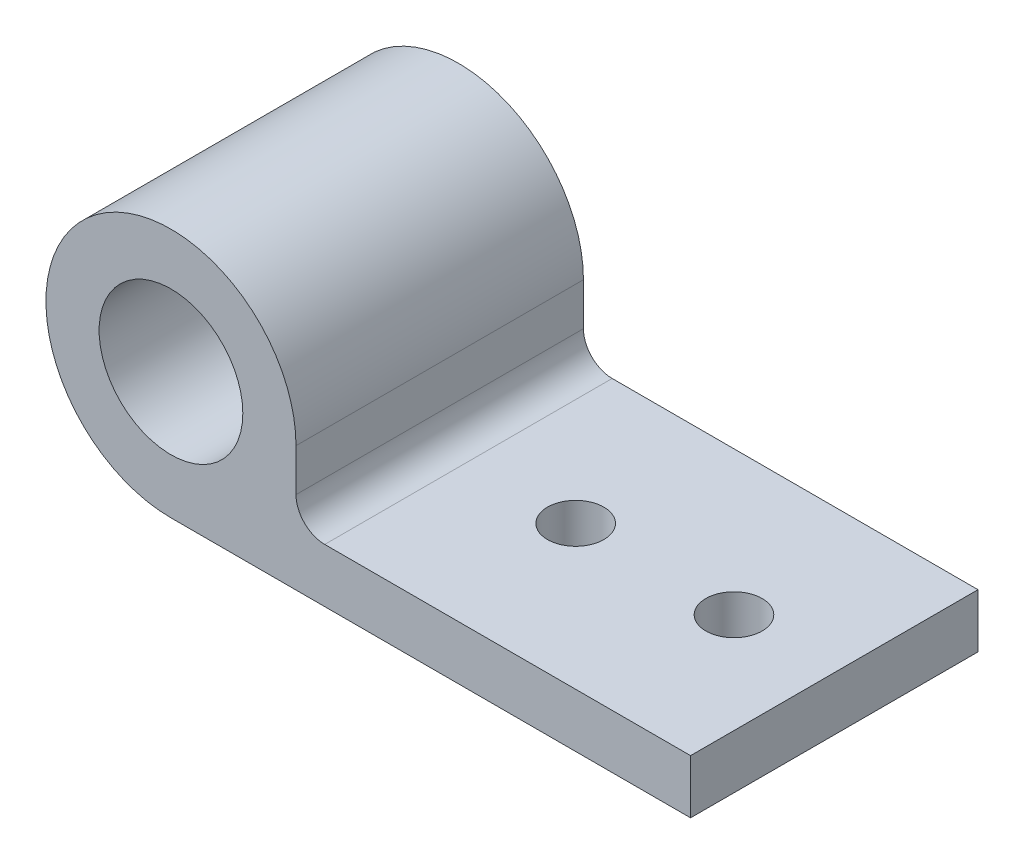
from build123d import *

# Parameters (mm, degrees)
SKETCH1_R           = 6.35
BOSS_EXTRUDE1_DEPTH = 25.4
FILLET1_R           = 2.54
SKETCH2_R           = 2.4892
CUT_EXTRUDE1_DEPTH  = 5.7625


with BuildPart() as part:
    # Sketch1 → Boss-Extrude1 (new body)
    with BuildSketch(Plane.XY):
        with BuildLine():
            Line((11.049, -6.2865), (11.049, 0))
            ThreePointArc((11.049, 0), (-7.812822825, 7.812822825), (0, -11.049))
            Line((0, -11.049), (45.91627088, -11.049))
            Line((45.91627088, -11.049), (45.91627088, -6.2865))
            Line((45.91627088, -6.2865), (11.049, -6.2865))
        make_face()
        with Locations((0, 0.127)):
            Circle(SKETCH1_R, mode=Mode.SUBTRACT)
    extrude(amount=BOSS_EXTRUDE1_DEPTH)

    # Fillet1
    fillet1_edges = [part.edges().sort_by_distance(p)[0] for p in [
        (11.049, -6.2865, 12.7),
    ]]
    fillet(fillet1_edges, radius=FILLET1_R)

    # Sketch2 → Cut-Extrude1 (cut, through all)
    with BuildSketch(Plane(origin=(0, -6.2865, 0), x_dir=(1, 0, 0), z_dir=(0, 1, 0))):
        with Locations(Location((37.052858889, -12.7, 0), (0, 0, 180))):  # turned: the seam where the file's is
            Circle(SKETCH2_R)
        with Locations(Location((23.063244992, -12.7, 0), (0, 0, 180))):  # turned: the seam where the file's is
            Circle(SKETCH2_R)
    extrude(amount=-CUT_EXTRUDE1_DEPTH, mode=Mode.SUBTRACT)


solid = part.part
